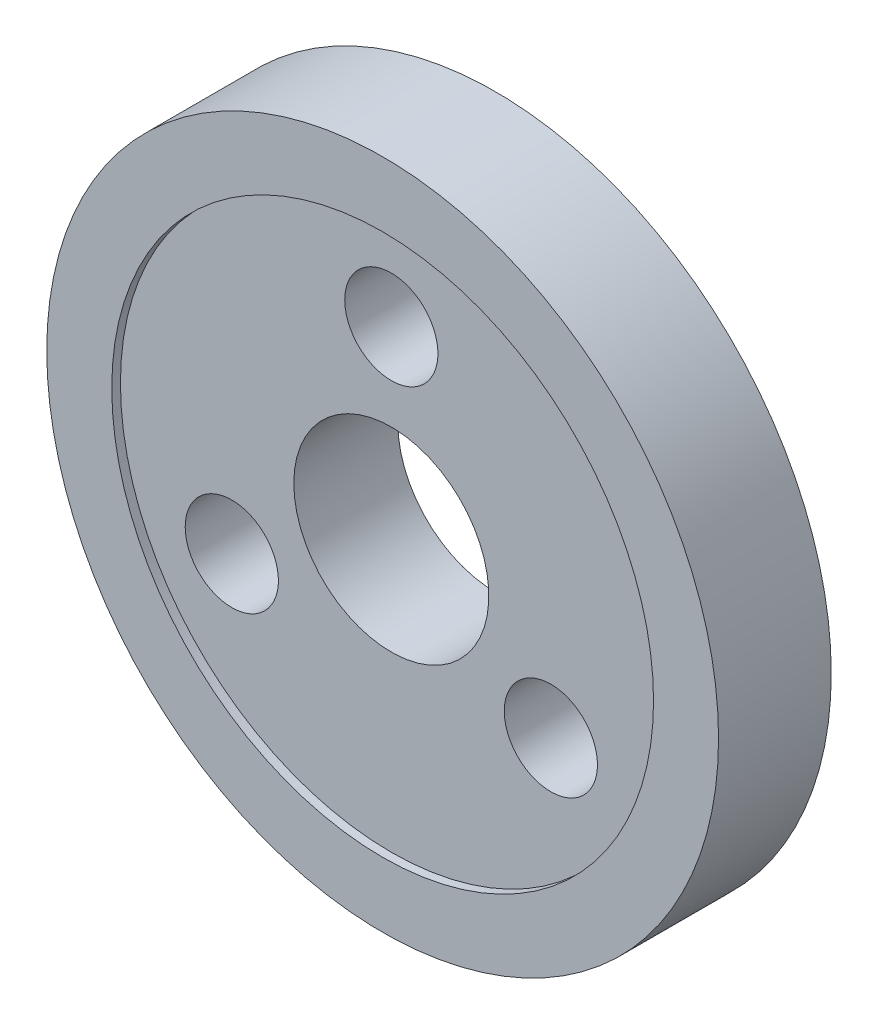
from build123d import *

# Parameters (mm, degrees)
SKETCH1_R            = 15.5
SKETCH1_R_2          = 12.5
BOSS_EXTRUDE1_DEPTH  = 0.4
SKETCH2_R            = 15.5
SKETCH2_R_2          = 4.5
BOSS_EXTRUDE2_DEPTH  = 4.8
M4_CLEARANCE_HOLE1_D = 4.3


with BuildPart() as part:
    # Sketch1 → Boss-Extrude1 (new body)
    with BuildSketch(Plane.XY):
        Circle(SKETCH1_R)
        Circle(SKETCH1_R_2, mode=Mode.SUBTRACT)
    extrude(amount=BOSS_EXTRUDE1_DEPTH)

    # Sketch2 → Boss-Extrude2 (add)
    with BuildSketch(Plane(origin=(0, 0, 0), x_dir=(-1, 0, 0), z_dir=(0, 0, -1))):
        Circle(SKETCH2_R)
        Circle(SKETCH2_R_2, mode=Mode.SUBTRACT)
    extrude(amount=BOSS_EXTRUDE2_DEPTH)

    # M4 Clearance Hole1 (through all)
    with Locations(Plane(origin=(0, 0, -4.8), x_dir=(-1, 0, 0), z_dir=(0, 0, -1))):
        with Locations((0, 8.5), (7.361215932, -4.25), (-7.361215932, -4.25)):
            Hole(M4_CLEARANCE_HOLE1_D / 2)


solid = part.part
